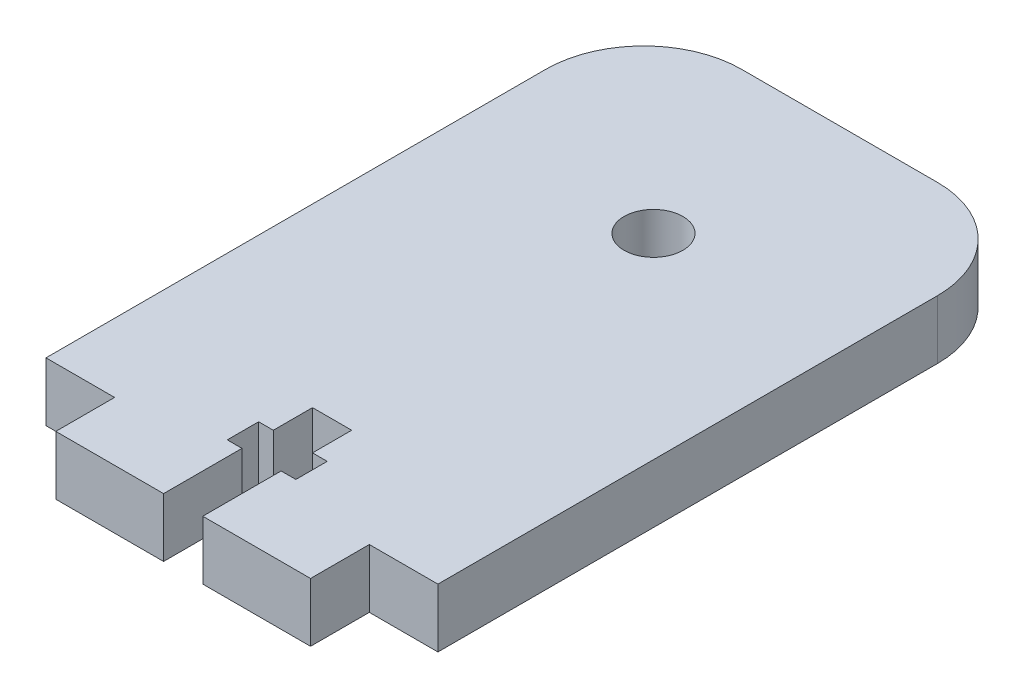
from build123d import *

# Parameters (mm, degrees)
SKETCH1_R           = 3
BOSS_EXTRUDE2_DEPTH = 6


with BuildPart() as part:
    # Sketch1 → Boss-Extrude2 (new body)
    with BuildSketch(Plane(origin=(0, 0, 0), x_dir=(1, 0, 0), z_dir=(0, 1, 0))):
        with BuildLine():
            Line((-10.520184167, 63), (9.479815833, 63))
            ThreePointArc((9.479815833, 63), (16.550883645, 60.071067812), (19.479815833, 53))
            Line((19.479815833, 53), (19.479815833, 2))
            Line((19.479815833, 2), (12.479815833, 2))
            Line((12.479815833, 2), (12.479815833, -4))
            Line((12.479815833, -4), (1.479815833, -4))
            Line((1.479815833, -4), (1.479815833, 4))
            Line((1.479815833, 4), (2.979815833, 4))
            Line((2.979815833, 4), (2.979815833, 7.2))
            Line((2.979815833, 7.2), (1.479815833, 7.2))
            Line((1.479815833, 7.2), (1.479815833, 11.2))
            Line((1.479815833, 11.2), (-2.520184167, 11.2))
            Line((-2.520184167, 11.2), (-2.520184167, 7.2))
            Line((-2.520184167, 7.2), (-4.020184167, 7.2))
            Line((-4.020184167, 7.2), (-4.020184167, 4))
            Line((-4.020184167, 4), (-2.520184167, 4))
            Line((-2.520184167, 4), (-2.520184167, -4))
            Line((-2.520184167, -4), (-13.520184167, -4))
            Line((-13.520184167, -4), (-13.520184167, 2))
            Line((-13.520184167, 2), (-20.520184167, 2))
            Line((-20.520184167, 2), (-20.520184167, 53))
            ThreePointArc((-20.520184167, 53), (-17.591251979, 60.071067812), (-10.520184167, 63))
        make_face()
        with Locations((-0.520184167, 44)):
            Circle(SKETCH1_R, mode=Mode.SUBTRACT)
    extrude(amount=-BOSS_EXTRUDE2_DEPTH)


solid = part.part
